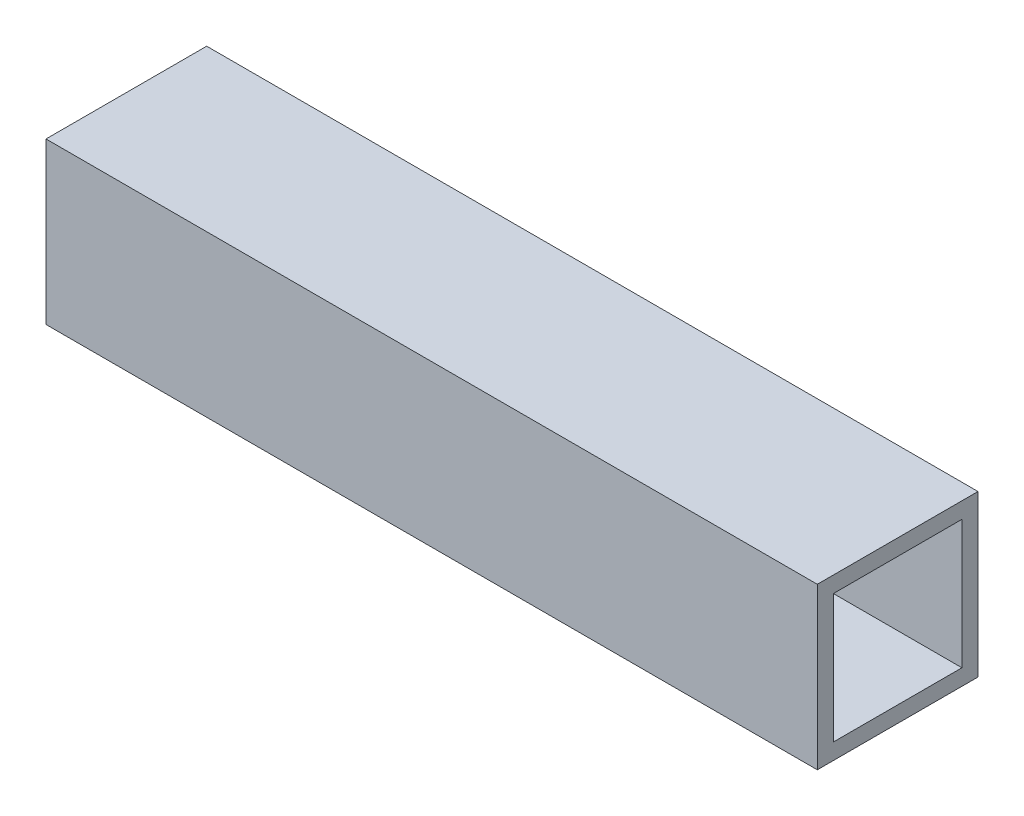
from build123d import *

# Parameters (mm, degrees)
SKETCH1_W           = 31.75
SKETCH1_H           = 31.75
SKETCH1_W_2         = 25.4
SKETCH1_H_2         = 25.4
BOSS_EXTRUDE1_DEPTH = 76.2


with BuildPart() as part:
    # Sketch1 → Boss-Extrude1 (new body, symmetric)
    with BuildSketch(Plane(origin=(0, 0, 0), x_dir=(0, 0, -1), z_dir=(1, 0, 0))):
        Rectangle(SKETCH1_W, SKETCH1_H)
        Rectangle(SKETCH1_W_2, SKETCH1_H_2, mode=Mode.SUBTRACT)
    extrude(amount=BOSS_EXTRUDE1_DEPTH, both=True)


solid = part.part
